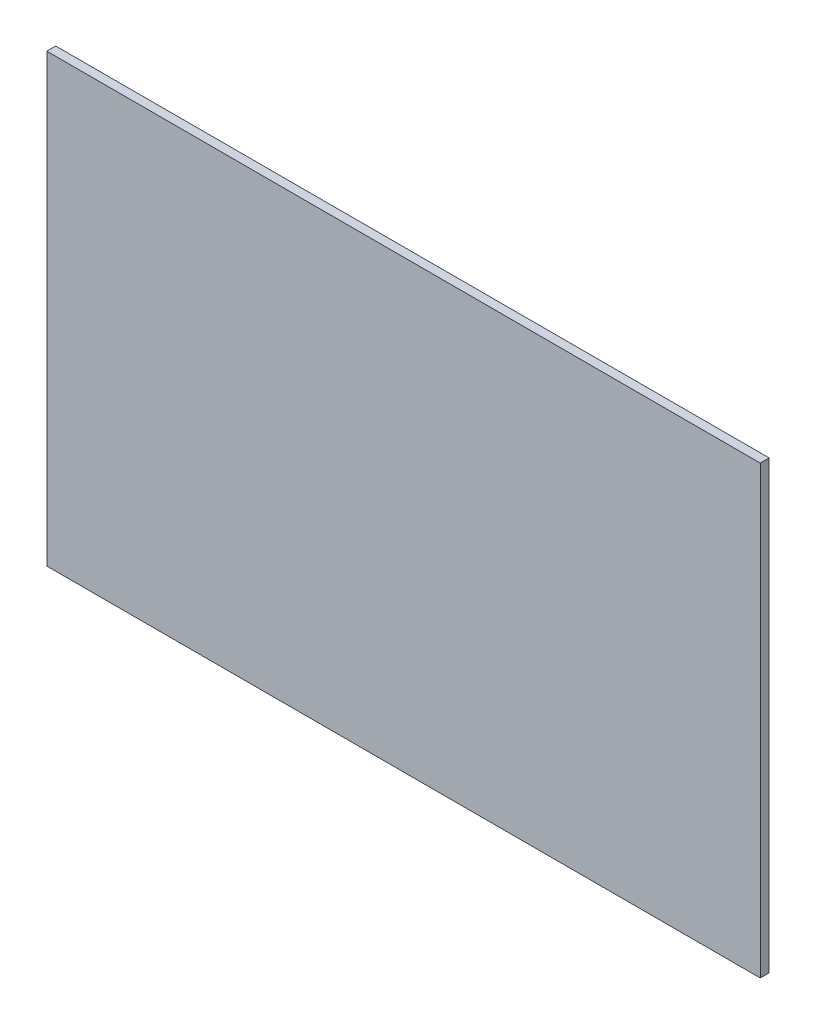
from build123d import *

# Parameters (mm, degrees)
ESQUISSE1_W        = 160
ESQUISSE1_H        = 100
BOSS_EXTRU_1_DEPTH = 2


with BuildPart() as part:
    # Esquisse1 → Boss.-Extru.1 (new body)
    with BuildSketch(Plane.XY):
        Rectangle(ESQUISSE1_W, ESQUISSE1_H)
    extrude(amount=BOSS_EXTRU_1_DEPTH)


solid = part.part
